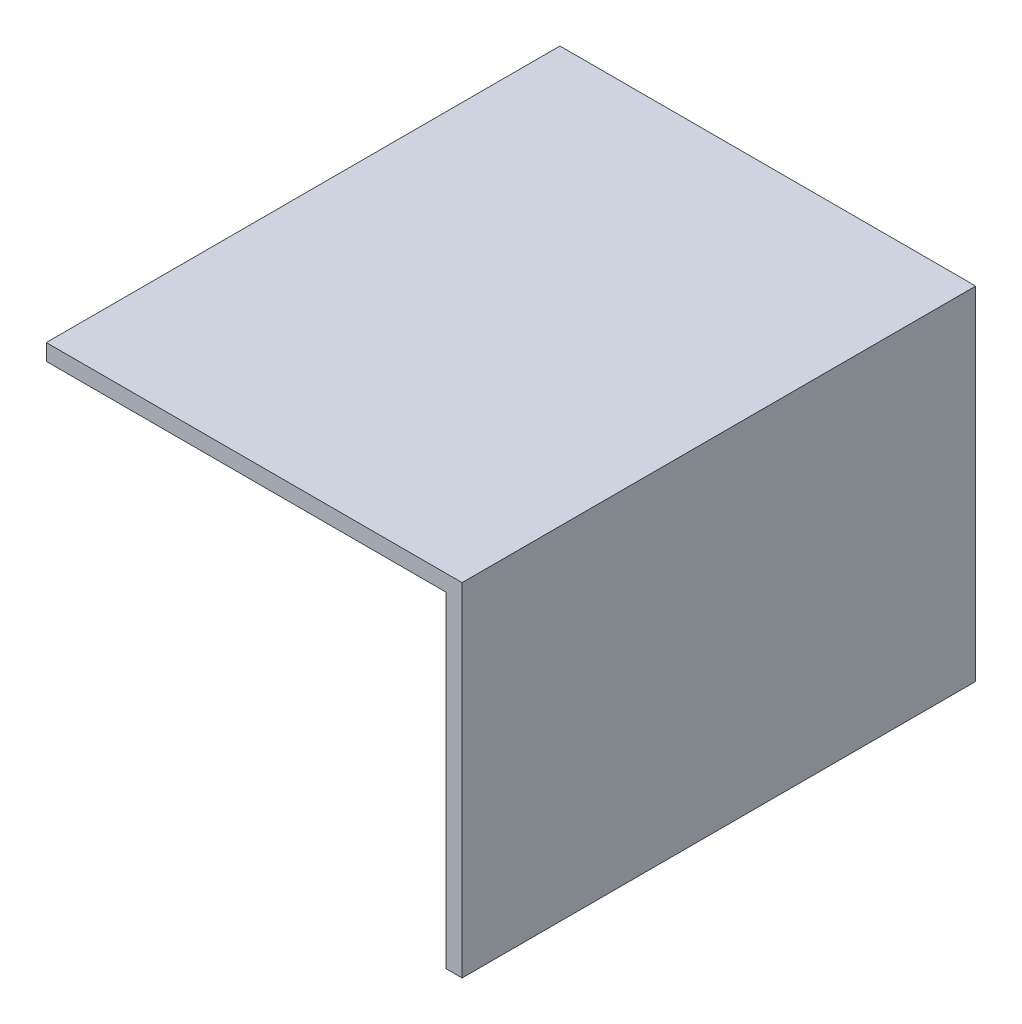
from build123d import *

# Parameters (mm, degrees)
SKETCH1_W           = 51
SKETCH1_H           = 63
BOSS_EXTRUDE1_DEPTH = 42
SKETCH3_W           = 49
SKETCH3_H           = 63
CUT_EXTRUDE2_DEPTH  = 40


with BuildPart() as part:
    # Sketch1 → Boss-Extrude1 (new body)
    with BuildSketch(Plane(origin=(0, 0, 0), x_dir=(1, 0, 0), z_dir=(0, 1, 0))):
        Rectangle(SKETCH1_W, SKETCH1_H)
    extrude(amount=BOSS_EXTRUDE1_DEPTH)

    # Sketch3 → Cut-Extrude2 (cut)
    with BuildSketch(Plane(origin=(0, 0, 0), x_dir=(-1, 0, 0), z_dir=(0, -1, 0))):
        with Locations((1, 0)):
            Rectangle(SKETCH3_W, SKETCH3_H)
    extrude(amount=-CUT_EXTRUDE2_DEPTH, mode=Mode.SUBTRACT)


solid = part.part
